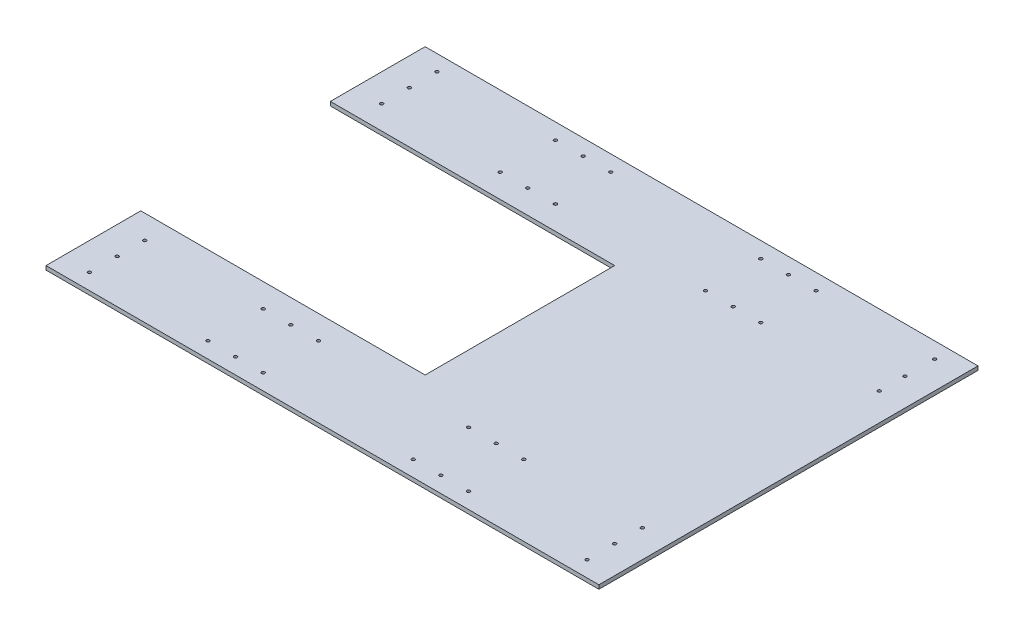
from build123d import *

# Parameters (mm, degrees)
SKETCH1_W           = 889
SKETCH1_H           = 609.6
BOSS_EXTRUDE1_DEPTH = 6.35
SKETCH2_W           = 457.2
SKETCH2_H           = 304.8
CUT_EXTRUDE1_DEPTH  = 6.35
SKETCH3_R           = 2.5527
CUT_EXTRUDE2_DEPTH  = 6.35


with BuildPart() as part:
    # Sketch1 → Boss-Extrude1 (new body)
    with BuildSketch(Plane(origin=(0, 0, 0), x_dir=(1, 0, 0), z_dir=(0, 1, 0))):
        with Locations((444.5, 304.8)):
            Rectangle(SKETCH1_W, SKETCH1_H)
    extrude(amount=BOSS_EXTRUDE1_DEPTH)

    # Sketch2 → Cut-Extrude1 (cut)
    with BuildSketch(Plane(origin=(0, 6.35, 0), x_dir=(1, 0, 0), z_dir=(0, 1, 0))):
        with Locations((228.6, 304.8)):
            Rectangle(SKETCH2_W, SKETCH2_H)
    extrude(amount=-CUT_EXTRUDE1_DEPTH, mode=Mode.SUBTRACT)

    # Sketch3 → Cut-Extrude2 (cut)
    with BuildSketch(Plane(origin=(0, 6.35, 0), x_dir=(1, 0, 0), z_dir=(0, 1, 0))):
        with Locations((44.45, 584.2)):
            Circle(SKETCH3_R)
        with Locations((44.45, 539.75)):
            Circle(SKETCH3_R)
        with Locations((44.45, 495.3)):
            Circle(SKETCH3_R)
        with Locations((44.45, 114.3)):
            Circle(SKETCH3_R)
        with Locations((44.45, 69.85)):
            Circle(SKETCH3_R)
        with Locations((44.45, 25.4)):
            Circle(SKETCH3_R)
        with Locations((234.95, 584.2)):
            Circle(SKETCH3_R)
        with Locations((279.4, 584.2)):
            Circle(SKETCH3_R)
        with Locations((323.85, 584.2)):
            Circle(SKETCH3_R)
        with Locations((234.95, 495.3)):
            Circle(SKETCH3_R)
        with Locations((279.4, 495.3)):
            Circle(SKETCH3_R)
        with Locations((323.85, 495.3)):
            Circle(SKETCH3_R)
        with Locations((234.95, 114.3)):
            Circle(SKETCH3_R)
        with Locations((279.4, 114.3)):
            Circle(SKETCH3_R)
        with Locations((323.85, 114.3)):
            Circle(SKETCH3_R)
        with Locations((234.95, 25.4)):
            Circle(SKETCH3_R)
        with Locations((279.4, 25.4)):
            Circle(SKETCH3_R)
        with Locations((323.85, 25.4)):
            Circle(SKETCH3_R)
        with Locations((565.15, 584.2)):
            Circle(SKETCH3_R)
        with Locations((565.15, 495.3)):
            Circle(SKETCH3_R)
        with Locations((609.6, 584.2)):
            Circle(SKETCH3_R)
        with Locations((609.6, 495.3)):
            Circle(SKETCH3_R)
        with Locations((654.05, 584.2)):
            Circle(SKETCH3_R)
        with Locations((654.05, 495.3)):
            Circle(SKETCH3_R)
        with Locations((565.15, 114.3)):
            Circle(SKETCH3_R)
        with Locations((609.6, 114.3)):
            Circle(SKETCH3_R)
        with Locations((654.05, 114.3)):
            Circle(SKETCH3_R)
        with Locations((565.15, 25.4)):
            Circle(SKETCH3_R)
        with Locations((609.6, 25.4)):
            Circle(SKETCH3_R)
        with Locations((654.05, 25.4)):
            Circle(SKETCH3_R)
        with Locations((844.55, 584.2)):
            Circle(SKETCH3_R)
        with Locations((844.55, 536.575)):
            Circle(SKETCH3_R)
        with Locations((844.55, 495.3)):
            Circle(SKETCH3_R)
        with Locations((844.55, 114.3)):
            Circle(SKETCH3_R)
        with Locations((844.55, 69.85)):
            Circle(SKETCH3_R)
        with Locations((844.55, 25.4)):
            Circle(SKETCH3_R)
    extrude(amount=-CUT_EXTRUDE2_DEPTH, mode=Mode.SUBTRACT)


solid = part.part
